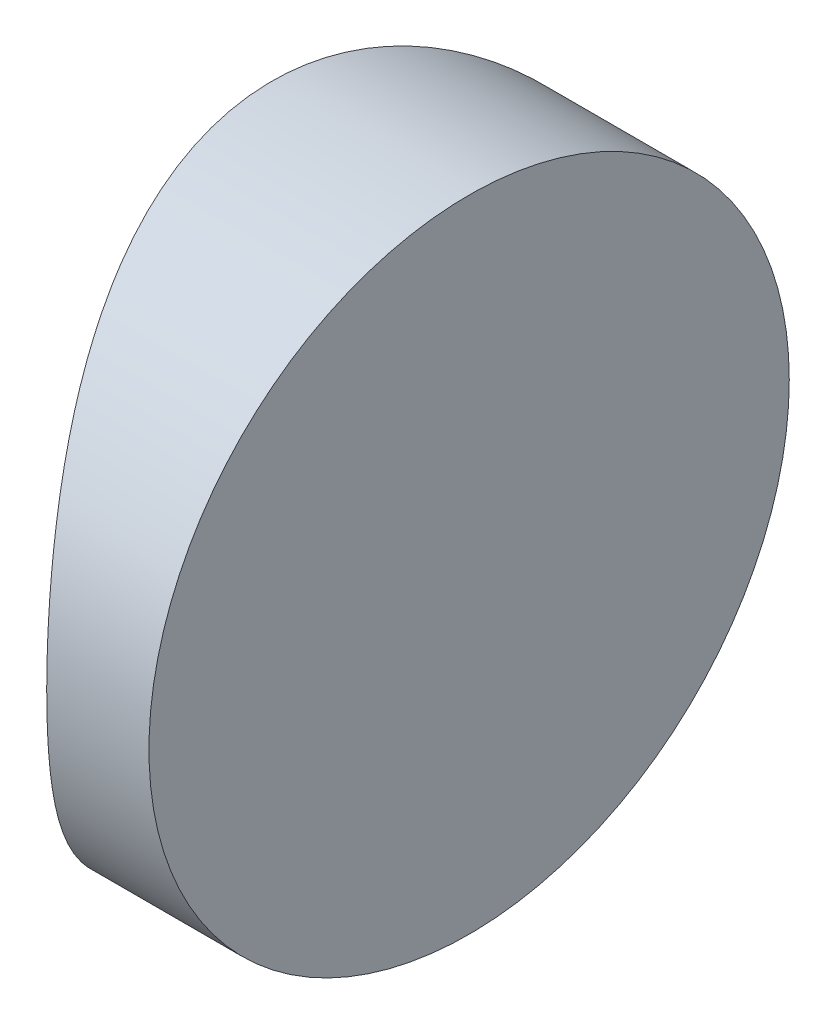
from build123d import *

# Parameters (mm, degrees)
EXTRUDE_1_DEPTH     = 12.5
CUT_EXTRUDE_8_DEPTH = 12.7


with BuildPart() as part:
    # 草图1 → 凸台-拉伸1 (new body)
    with BuildSketch(Plane(origin=(0, 0, 0), x_dir=(1, 0, 0), z_dir=(0, 1, 0))):
        with BuildLine():
            Line((-5.250476276, 6.25), (-3.254795665, 6.25))
            Line((-3.254795665, 6.25), (-3.254795665, -6.25))
            Line((-3.254795665, -6.25), (-5.250476276, -6.25))
            ThreePointArc((-5.250476276, -6.25), (-7.104795665, 0), (-5.250476276, 6.25))
        make_face()
    extrude(amount=EXTRUDE_1_DEPTH)

    # 草图2 → 切除-拉伸8 (cut)
    with BuildSketch(Plane(origin=(-3.254795665, 0, 0), x_dir=(0, 0, -1), z_dir=(1, 0, 0))):
        with BuildLine():
            Line((-6.25, 12.5), (-6.25, 6.25))
            ThreePointArc((-6.25, 6.25), (-4.419417382, 10.669417382), (0, 12.5))
            Line((0, 12.5), (-6.25, 12.5))
        make_face()
        with BuildLine():
            ThreePointArc((0, 12.5), (4.419417382, 10.669417382), (6.25, 6.25))
            Line((6.25, 6.25), (6.25, 12.5))
            Line((6.25, 12.5), (0, 12.5))
        make_face()
        with BuildLine():
            ThreePointArc((6.25, 6.25), (4.419417382, 1.830582618), (0, 0))
            Line((0, 0), (6.25, 0))
            Line((6.25, 0), (6.25, 6.25))
        make_face()
        with BuildLine():
            Line((-6.25, 6.25), (-6.25, 0))
            Line((-6.25, 0), (0, 0))
            ThreePointArc((0, 0), (-4.419417382, 1.830582618), (-6.25, 6.25))
        make_face()
    extrude(amount=-CUT_EXTRUDE_8_DEPTH, mode=Mode.SUBTRACT)


solid = part.part
